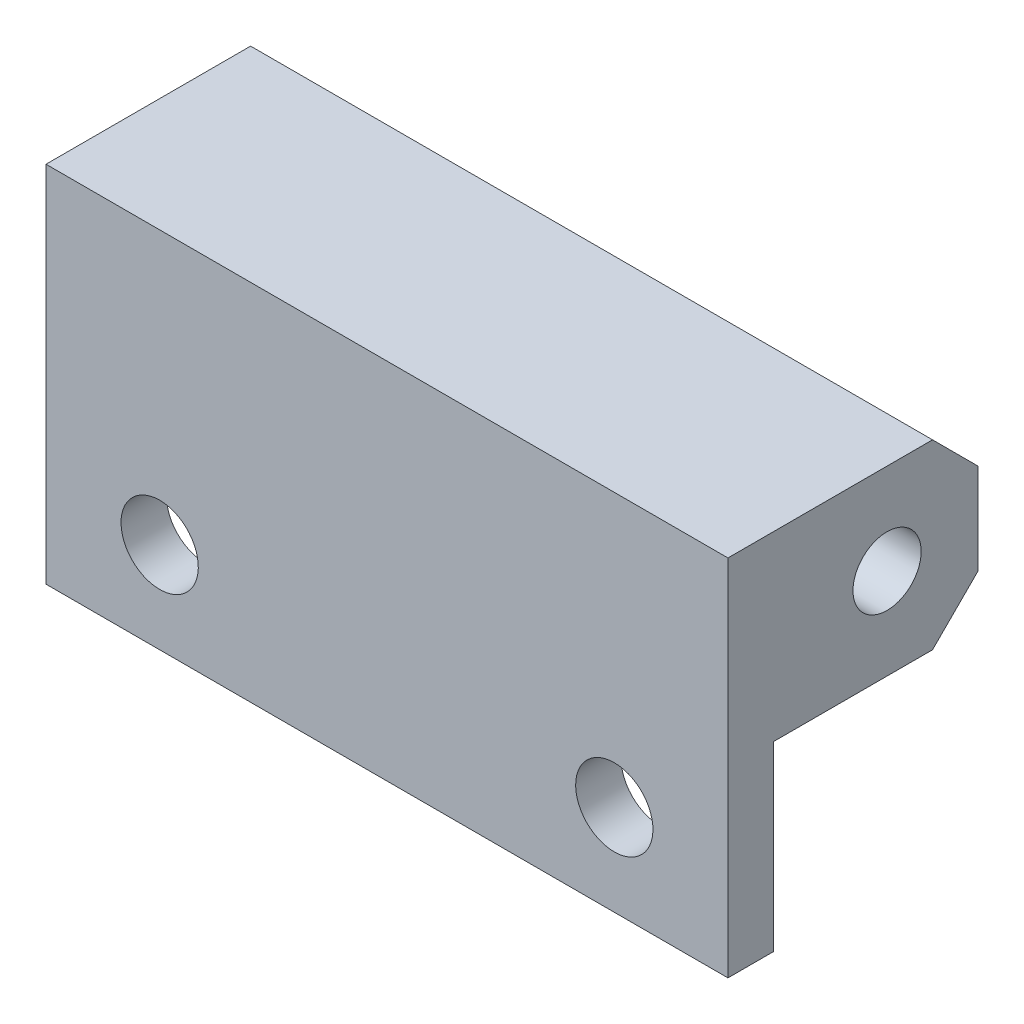
from build123d import *

# Parameters (mm, degrees)
BOSS_EXTRUDE1_DEPTH     = 15
M3_CLEARANCE_HOLE1_D    = 3.4
SKETCH4_R               = 1.5
CUT_EXTRUDE1_DEPTH      = 1
CUT_EXTRUDE1_DEPTH_BACK = 31


with BuildPart() as part:
    # Sketch1 → Boss-Extrude1 (new body, symmetric)
    with BuildSketch(Plane(origin=(0, 0, 0), x_dir=(0, 0, -1), z_dir=(1, 0, 0))):
        Polygon((-7, 4), (2, 4), (4, 2), (4, -2), (2, -4), (-5, -4), (-5, -12), (-7, -12), align=None)
    extrude(amount=BOSS_EXTRUDE1_DEPTH, both=True)

    # M3 Clearance Hole1 (through all)
    with Locations(Plane(origin=(0, 0, 5), x_dir=(-1, 0, 0), z_dir=(0, 0, -1))):
        with Locations((-10, -8), (10, -8)):
            Hole(M3_CLEARANCE_HOLE1_D / 2)

    # Sketch4 → Cut-Extrude1 (cut, two sides)
    with BuildSketch(Plane(origin=(15, 0, 0), x_dir=(0, 0, -1), z_dir=(1, 0, 0))) as cut_extrude1_sk:
        Circle(SKETCH4_R)
    extrude(amount=CUT_EXTRUDE1_DEPTH, mode=Mode.SUBTRACT)
    extrude(cut_extrude1_sk.sketch, amount=-CUT_EXTRUDE1_DEPTH_BACK, mode=Mode.SUBTRACT)


solid = part.part
